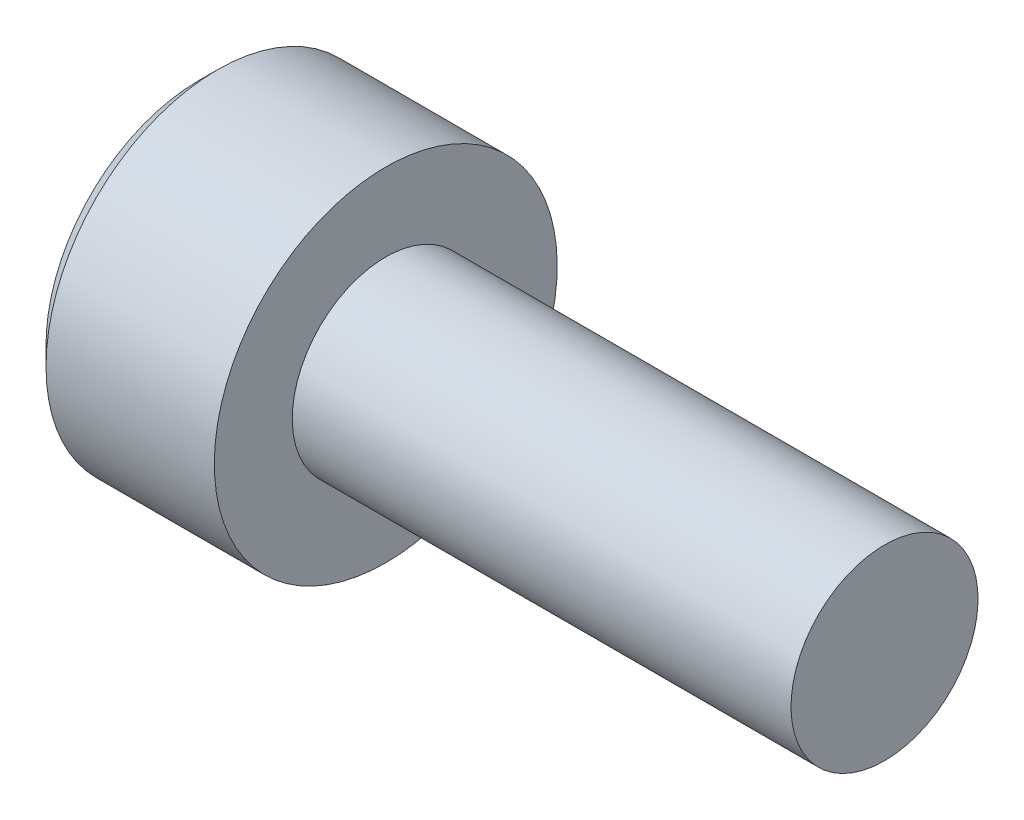
from build123d import *

# Parameters (mm, degrees)
CUT_EXTRUDE1_DEPTH = 1.3
CHAMFER1_SIZE      = 0.3


with BuildPart() as part:
    # Sketch1 → Revolve1 (revolve)
    with BuildSketch(Plane.XY):
        Polygon((0, 1.5), (8, 1.5), (8, 0), (-3, 0), (-3, 2.75), (0, 2.75), align=None)
    revolve(axis=Axis((-3, 0, 0), (1, 0, 0)))

    # Sketch2 → Cut-Revolve1 (revolve, cut)
    with BuildSketch(Plane.XY):
        Polygon((-0.948924226, 0), (-1.7, 1.25), (-3, 1.25), (-3, 0), align=None)
    revolve(axis=Axis((-3, 0, 0), (1, 0, 0)), mode=Mode.SUBTRACT)

    # Sketch3 → Cut-Extrude1 (cut)
    with BuildSketch(Plane.ZY.offset(3)):
        Polygon((1.25, 0.721687836), (0, 1.443375673), (-1.25, 0.721687836), (-1.25, -0.721687836), (0, -1.443375673), (1.25, -0.721687836), align=None)
    extrude(amount=-CUT_EXTRUDE1_DEPTH, mode=Mode.SUBTRACT)

    # Chamfer1
    chamfer1_edges = [part.edges().sort_by_distance(p)[0] for p in [
        (-3, -2.75, 0),
    ]]
    chamfer(chamfer1_edges, length=CHAMFER1_SIZE)


solid = part.part
